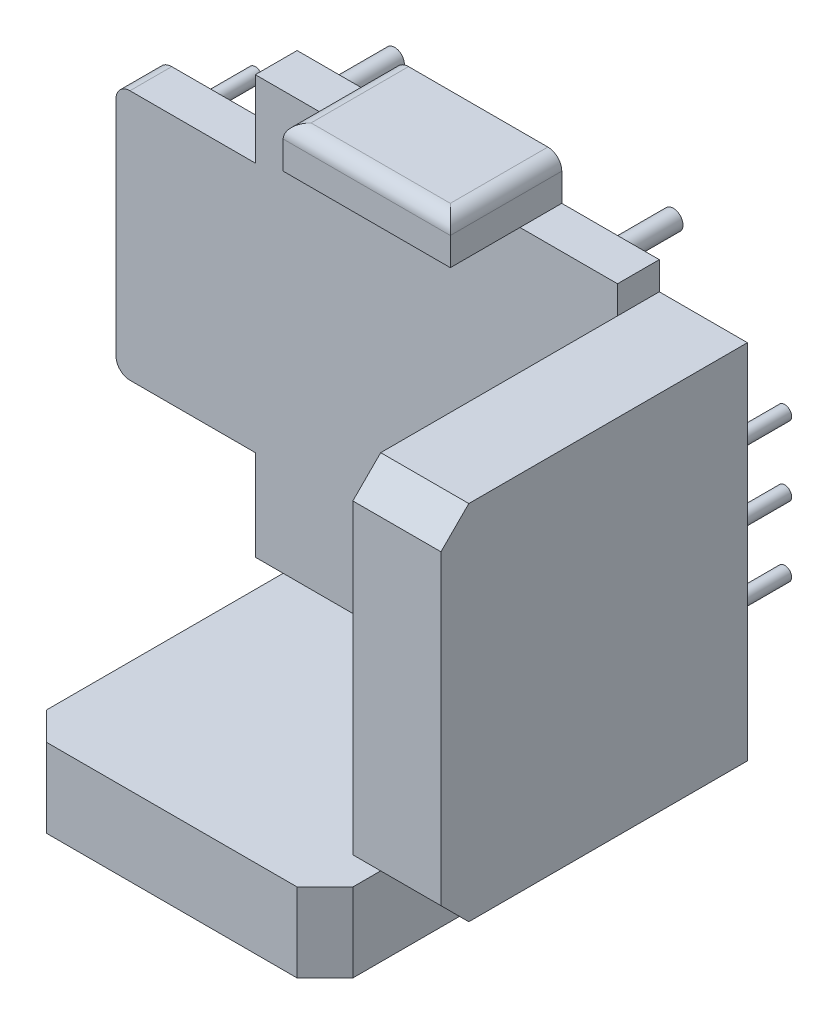
from build123d import *

# Parameters (mm, degrees)
RESSALTO_EXTRUS_O4_DEPTH  = 1.5
ESBO_O5_W                 = 6
ESBO_O5_H                 = 1.5
RESSALTO_EXTRUS_O6_DEPTH  = 4
RESSALTO_EXTRUS_O7_DEPTH  = 11
ESBO_O8_W                 = 2.01
ESBO_O8_H                 = 1.51
RESSALTO_EXTRUS_O15_DEPTH = 11
ESBO_O9_W                 = 1.51
ESBO_O9_H                 = 2.01
RESSALTO_EXTRUS_O16_DEPTH = 11
ESBO_O10_R                = 0.25
RESSALTO_EXTRUS_O17_DEPTH = 2.5
ESBO_O11_R                = 0.35
RESSALTO_EXTRUS_O18_DEPTH = 4
ESBO_O12_R                = 0.25
RESSALTO_EXTRUS_O19_DEPTH = 2.5
CHANFRO1_SIZE             = 1
FILETE2_R                 = 0.5


with BuildPart() as part:
    # Esboço3 → Ressalto-extrusão4 (new body)
    with BuildSketch(Plane(origin=(0, 0, 0), x_dir=(-1, 0, 0), z_dir=(0, 0, -1))):
        Polygon((11.5, 4.75), (6.5, 4.75), (6.5, 7.5), (-6.5, 7.5), (-6.5, 6.5), (-8.5, 6.5), (-8.5, 5), (-6.5, 5), (-6.5, -5), (-8.5, -5), (-8.5, -6.5), (-6.5, -6.5), (-6.5, -7.5), (-5.5, -7.5), (-5.5, -9.5), (-4, -9.5), (-4, -7.5), (4, -7.5), (4, -9.5), (5.5, -9.5), (5.5, -7.5), (6.5, -7.5), (6.5, -4.25), (11.5, -4.25), align=None)
    extrude(amount=RESSALTO_EXTRUS_O4_DEPTH)

    # Esboço5 → Ressalto-extrusão6 (add)
    with BuildSketch(Plane(origin=(0, 0, -1.5), x_dir=(-1, 0, 0), z_dir=(0, 0, -1))):
        with Locations((0, 8.25)):
            Rectangle(ESBO_O5_W, ESBO_O5_H)
    extrude(amount=-RESSALTO_EXTRUS_O6_DEPTH)

    # Esboço6 → Ressalto-extrusão7 (add)
    with BuildSketch(Plane(origin=(0, 0, -1.5), x_dir=(-1, 0, 0), z_dir=(0, 0, -1))):
        Polygon((-6.5, 4.99), (-8.51, 4.99), (-8.51, 6.5), (-9.663134603, 6.5), (-9.663134603, -6.5), (-8.51, -6.5), (-8.51, -4.99), (-6.5, -4.99), align=None)
        Polygon((-3.99, -7.5), (-3.99, -9.51), (-5.5, -9.51), (-5.5, -10.329816926), (5.5, -10.329816926), (5.5, -9.51), (3.99, -9.51), (3.99, -7.5), align=None)
    extrude(amount=-RESSALTO_EXTRUS_O7_DEPTH)

    # Esboço8 → Ressalto-extrusão15 (add)
    with BuildSketch(Plane.XY.offset(9.5)):
        with Locations((7.505, -5.745)):
            Rectangle(ESBO_O8_W, ESBO_O8_H)
        with Locations((7.505, 5.745)):
            Rectangle(ESBO_O8_W, ESBO_O8_H)
    extrude(amount=-RESSALTO_EXTRUS_O15_DEPTH)

    # Esboço9 → Ressalto-extrusão16 (add)
    with BuildSketch(Plane.XY.offset(9.5)):
        with Locations((-4.745, -8.505)):
            Rectangle(ESBO_O9_W, ESBO_O9_H)
        with Locations((4.745, -8.505)):
            Rectangle(ESBO_O9_W, ESBO_O9_H)
    extrude(amount=-RESSALTO_EXTRUS_O16_DEPTH)

    # Esboço10 → Ressalto-extrusão17 (add)
    with BuildSketch(Plane(origin=(0, 0, -1.5), x_dir=(-1, 0, 0), z_dir=(0, 0, -1))):
        with Locations((10.5, 3.5)):
            Circle(ESBO_O10_R)
        with Locations((6.5, 3.5)):
            Circle(ESBO_O10_R)
        with Locations((10.5, -3)):
            Circle(ESBO_O10_R)
        with Locations((6.5, -3)):
            Circle(ESBO_O10_R)
    extrude(amount=RESSALTO_EXTRUS_O17_DEPTH)

    # Esboço11 → Ressalto-extrusão18 (add)
    with BuildSketch(Plane.XY):
        with Locations((-5.5, 6.5)):
            Circle(ESBO_O11_R)
        with Locations((4.5, 6.5)):
            Circle(ESBO_O11_R)
        with Locations((4.5, -6.5)):
            Circle(ESBO_O11_R)
        with Locations((-5.5, -6.5)):
            Circle(ESBO_O11_R)
    extrude(amount=-RESSALTO_EXTRUS_O18_DEPTH)

    # Esboço12 → Ressalto-extrusão19 (add)
    with BuildSketch(Plane(origin=(0, 0, -1.5), x_dir=(-1, 0, 0), z_dir=(0, 0, -1))):
        with Locations((3, -8.5)):
            Circle(ESBO_O12_R)
        with Locations((0.5, -8.5)):
            Circle(ESBO_O12_R)
        with Locations((-2, -8.5)):
            Circle(ESBO_O12_R)
        with Locations((-8.5, -2.5)):
            Circle(ESBO_O12_R)
        with Locations((-8.5, 0)):
            Circle(ESBO_O12_R)
        with Locations((-8.5, 2.5)):
            Circle(ESBO_O12_R)
    extrude(amount=RESSALTO_EXTRUS_O19_DEPTH)

    # Chanfro1
    chanfro1_edges = [part.edges().sort_by_distance(p)[0] for p in [
        (-5.5, -8.914908463, 9.5),
        (5.5, -8.914908463, 9.5),
        (8.081567302, -6.5, 9.5),
        (8.081567302, 6.5, 9.5),
    ]]
    chamfer(chanfro1_edges, length=CHANFRO1_SIZE)

    # Filete2
    filete2_edges = [part.edges().sort_by_distance(p)[0] for p in [
        (-11.5, 4.75, -0.75),
        (-11.5, -4.25, -0.75),
        (-3, 9, 0.5),
        (0, 9, 2.5),
        (3, 9, 0.5),
    ]]
    fillet(filete2_edges, radius=FILETE2_R)


solid = part.part
